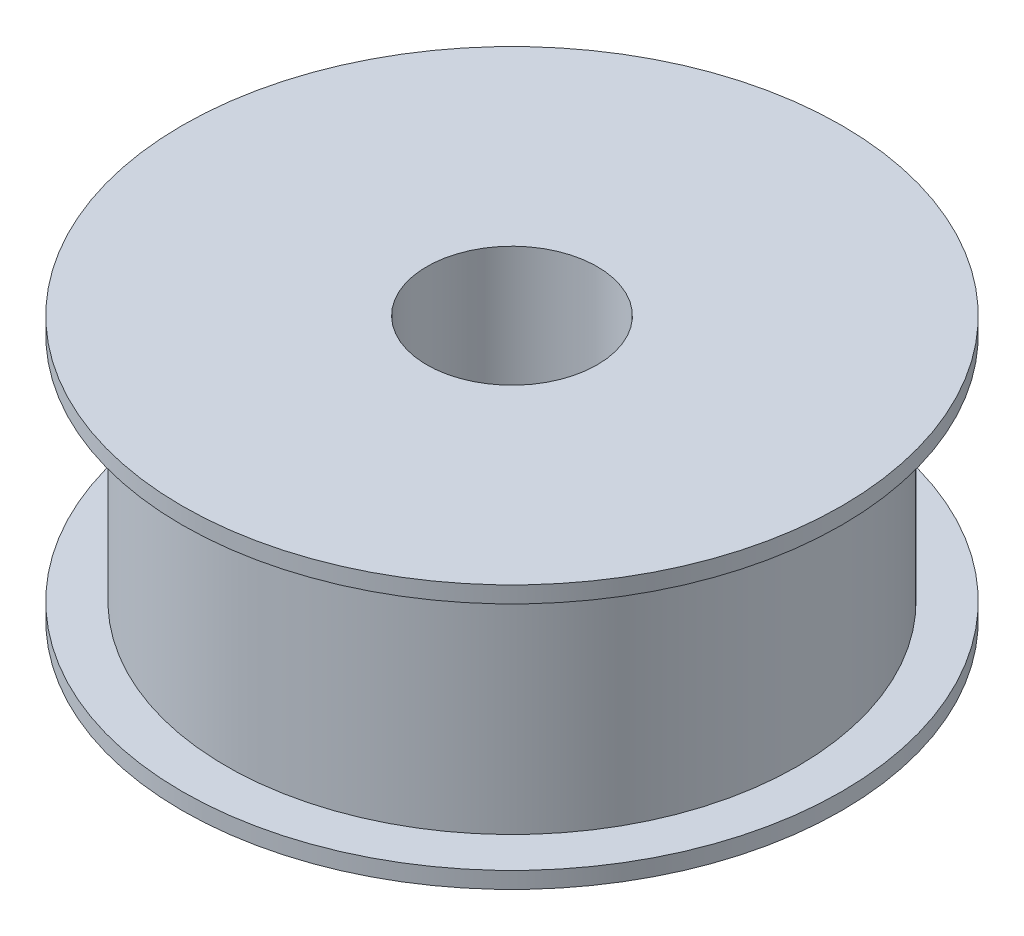
from build123d import *


with BuildPart() as part:
    # Sketch1 → Revolve1 (revolve)
    with BuildSketch(Plane.XY):
        Polygon((15.5, 24), (60, 24), (60, 21), (52, 21), (52, -21), (60, -21), (60, -24), (15.5, -24), align=None)
    revolve(axis=Axis((0, -523.100972672, 0), (0, 1, 0)))


solid = part.part
